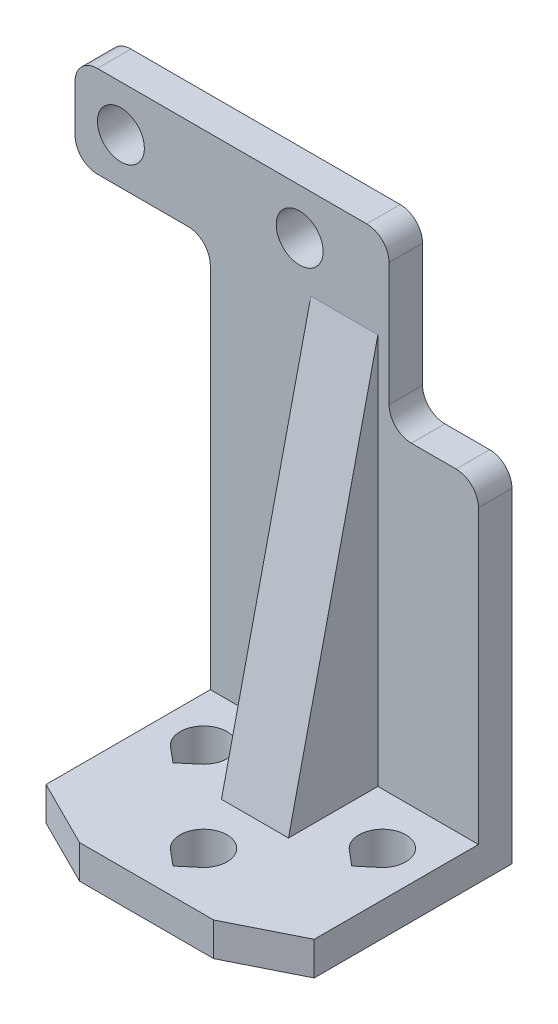
from build123d import *

# Parameters (mm, degrees)
SKETCH1_W           = 24
SKETCH1_H           = 17.7
BOSS_EXTRUDE1_DEPTH = 3
SKETCH2_R           = 2.1
BOSS_EXTRUDE2_DEPTH = 3
BOSS_EXTRUDE3_DEPTH = 3
CHAMFER1_SIZE       = 6
CHAMFER1_SIZE2      = 3
CHAMFER2_SIZE       = 3
CHAMFER2_SIZE2      = 6
FILLET1_R           = 2


with BuildPart() as part:
    # Sketch1 → Boss-Extrude1 (new body)
    with BuildSketch(Plane(origin=(0, 0, 0), x_dir=(1, 0, 0), z_dir=(0, 1, 0))):
        with Locations((0, -8.85)):
            Rectangle(SKETCH1_W, SKETCH1_H)
        with BuildLine():
            Line((-9.34985398, -6.208693331), (-8, -7.341355308))
            Line((-8, -7.341355308), (-6.65014602, -6.208693331))
            ThreePointArc((-6.65014602, -6.208693331), (-8, -2.5), (-9.34985398, -6.208693331))
        make_face(mode=Mode.SUBTRACT)
        with BuildLine():
            Line((6.65014602, -6.208693331), (8, -7.341355308))
            Line((8, -7.341355308), (9.34985398, -6.208693331))
            ThreePointArc((9.34985398, -6.208693331), (8, -2.5), (6.65014602, -6.208693331))
        make_face(mode=Mode.SUBTRACT)
        with BuildLine():
            Line((-1.34985398, -14.208693331), (0, -15.341355308))
            Line((0, -15.341355308), (1.34985398, -14.208693331))
            ThreePointArc((1.34985398, -14.208693331), (0, -10.5), (-1.34985398, -14.208693331))
        make_face(mode=Mode.SUBTRACT)
    extrude(amount=BOSS_EXTRUDE1_DEPTH)

    # Sketch2 → Boss-Extrude2 (add)
    with BuildSketch(Plane.XY):
        Polygon((12, 0), (-12, 0), (-12, 37.9), (-24.1, 37.9), (-24.1, 46.1), (-12, 46.1), (4, 46.1), (4, 31.1), (12, 31.1), align=None)
        with Locations((-20, 42)):
            Circle(SKETCH2_R, mode=Mode.SUBTRACT)
        with Locations((-4, 42)):
            Circle(SKETCH2_R, mode=Mode.SUBTRACT)
    extrude(amount=-BOSS_EXTRUDE2_DEPTH)

    # Sketch3 → Boss-Extrude3 (add, symmetric)
    with BuildSketch(Plane(origin=(0, 0, 0), x_dir=(0, 0, -1), z_dir=(1, 0, 0))):
        Polygon((0, 3), (-8, 3), (0, 38), align=None)
    extrude(amount=BOSS_EXTRUDE3_DEPTH, both=True)

    # Chamfer1
    chamfer1_edges = [part.edges().sort_by_distance(p)[0] for p in [
        (12, 1.5, 17.7),
    ]]
    chamfer1_side = [part.faces().sort_by_distance(p)[0] for p in [
        (0, 1.5, 17.7),
    ]]
    chamfer(chamfer1_edges, length=CHAMFER1_SIZE, length2=CHAMFER1_SIZE2, reference=chamfer1_side[0])

    # Chamfer2
    chamfer2_edges = [part.edges().sort_by_distance(p)[0] for p in [
        (-12, 1.5, 17.7),
    ]]
    chamfer2_side = [part.faces().sort_by_distance(p)[0] for p in [
        (-12, 1.5, 17.26815512),
    ]]
    chamfer(chamfer2_edges, length=CHAMFER2_SIZE, length2=CHAMFER2_SIZE2, reference=chamfer2_side[0])

    # Fillet1
    fillet1_edges = [part.edges().sort_by_distance(p)[0] for p in [
        (12, 31.1, -1.5),
        (-12, 37.9, -1.5),
        (-24.1, 37.9, -1.5),
        (-24.1, 46.1, -1.5),
        (4, 46.1, -1.5),
        (4, 31.1, -1.5),
    ]]
    fillet(fillet1_edges, radius=FILLET1_R)


solid = part.part
